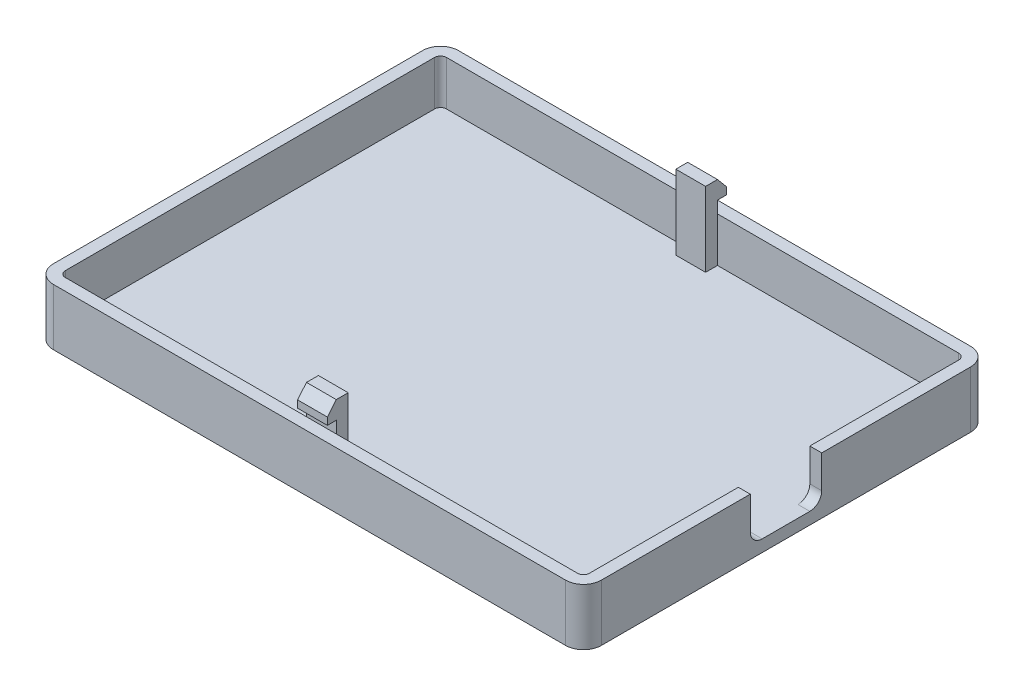
from build123d import *

# Parameters (mm, degrees)
SKETCH1_W           = 92
SKETCH1_H           = 68
BOSS_EXTRUDE1_DEPTH = 9.5
FILLET1_R           = 3
SHELL1_T            = -2
SKETCH3_W           = 5
SKETCH3_H           = 2
BOSS_EXTRUDE2_DEPTH = 12.5
BOSS_EXTRUDE3_DEPTH = 5
CUT_EXTRUDE1_REACH  = 94
SKETCH5_W           = 12
SKETCH5_H           = 7.5
FILLET2_R           = 2


with BuildPart() as part:
    # Sketch1 → Boss-Extrude1 (new body)
    with BuildSketch(Plane(origin=(0, 0, 0), x_dir=(1, 0, 0), z_dir=(0, 1, 0))):
        Rectangle(SKETCH1_W, SKETCH1_H)
    extrude(amount=BOSS_EXTRUDE1_DEPTH)

    # Fillet1
    fillet1_edges = [part.edges().sort_by_distance(p)[0] for p in [
        (46, 4.75, 34),
        (-46, 4.75, 34),
        (-46, 4.75, -34),
        (46, 4.75, -34),
    ]]
    fillet(fillet1_edges, radius=FILLET1_R)

    # Shell1
    shell1_openings = [part.faces().sort_by_distance(p)[0] for p in [
        (0, 9.5, 0),
    ]]
    offset(amount=SHELL1_T, openings=shell1_openings, kind=Kind.INTERSECTION)

    # Sketch3 → Boss-Extrude2 (add)
    with BuildSketch(Plane(origin=(0, 2, 0), x_dir=(1, 0, 0), z_dir=(0, 1, 0))):
        with Locations((0, 31)):
            Rectangle(SKETCH3_W, SKETCH3_H)
    boss_extrude2 = extrude(amount=BOSS_EXTRUDE2_DEPTH)

    # Sketch4 → Boss-Extrude3 (add)
    with BuildSketch(Plane.ZY.offset(2.5)):
        Polygon((-32, 14.5), (-33.5, 12.712369611), (-33.5, 11.5), (-32, 11.5), align=None)
    boss_extrude3 = extrude(amount=-BOSS_EXTRUDE3_DEPTH)

    # Mirror1: Boss-Extrude2, Boss-Extrude3 across plane
    add(boss_extrude2.mirror(Plane.XY))
    add(boss_extrude3.mirror(Plane.XY))

    # Sketch5 → Cut-Extrude1 (cut, up to next)
    with BuildSketch(Plane(origin=(46, 0, 0), x_dir=(0, 0, -1), z_dir=(1, 0, 0)), mode=Mode.PRIVATE) as cut_extrude1_sk1:
        with Locations((0, 5.75)):
            Rectangle(SKETCH5_W, SKETCH5_H)
    cut_extrude1_tool1 = extrude(cut_extrude1_sk1.sketch, amount=-CUT_EXTRUDE1_REACH, mode=Mode.PRIVATE) & part.part
    add(cut_extrude1_tool1.solids().sort_by_distance((46, 5.75, 0))[0], mode=Mode.SUBTRACT)

    # Fillet2
    fillet2_edges = [part.edges().sort_by_distance(p)[0] for p in [
        (45, 2, 6),
        (45, 2, -6),
    ]]
    fillet(fillet2_edges, radius=FILLET2_R)


solid = part.part
